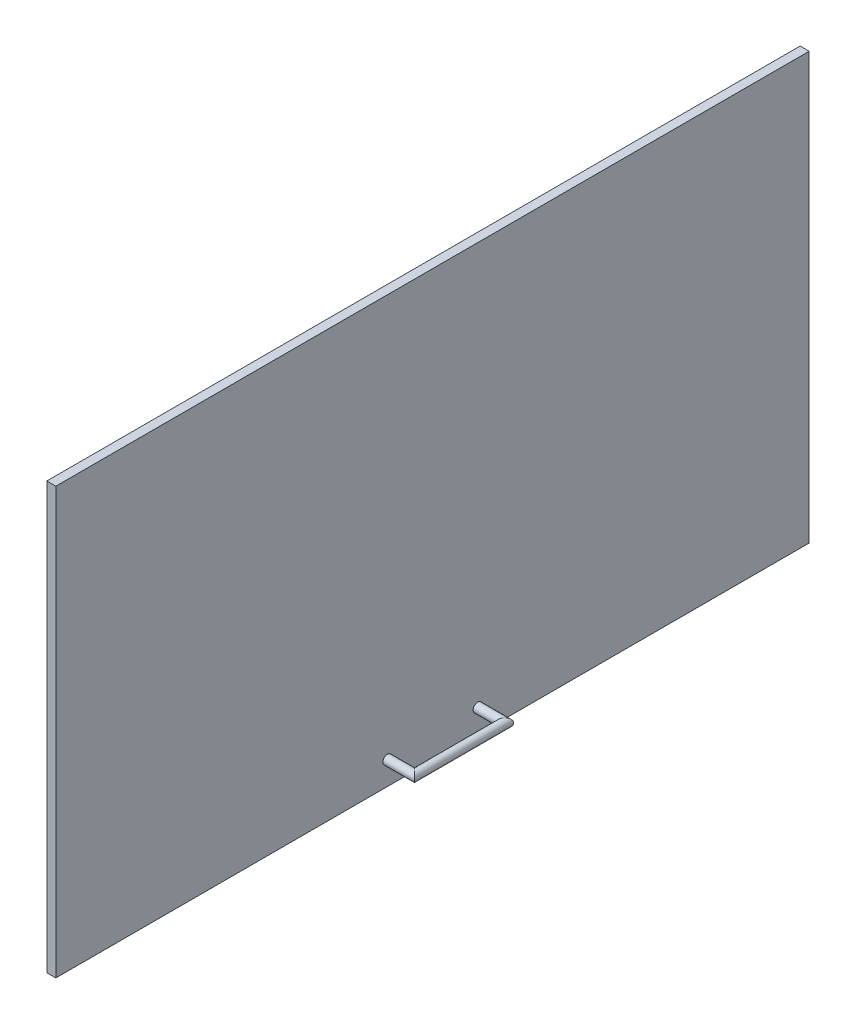
from build123d import *

# Parameters (mm, degrees)
SKETCH1_W           = 834.8
SKETCH1_H           = 471.91
BOSS_EXTRUDE1_DEPTH = 10
SKETCH2_R           = 5


with BuildPart() as part:
    # Sketch1 → Boss-Extrude1 (new body)
    with BuildSketch(Plane(origin=(0, 0, 0), x_dir=(0, 0, -1), z_dir=(1, 0, 0))):
        Rectangle(SKETCH1_W, SKETCH1_H)
    extrude(amount=BOSS_EXTRUDE1_DEPTH)

    # Sweep1: sweep along a curve in space
    with BuildLine() as sweep1_path:
        Line((10, -210, -50), (40, -210, -50))
        Line((40, -210, -50), (40, -210, 50))
        Line((10, -210, 50), (40, -210, 50))
    # Sketch2 → Sweep1 (sweep)
    with BuildSketch(Plane(origin=(10, 0, 0), x_dir=(0, 0, -1), z_dir=(1, 0, 0))):
        with Locations((50, -210)):
            Circle(SKETCH2_R)
    sweep(path=sweep1_path.line, transition=Transition.RIGHT)


solid = part.part
